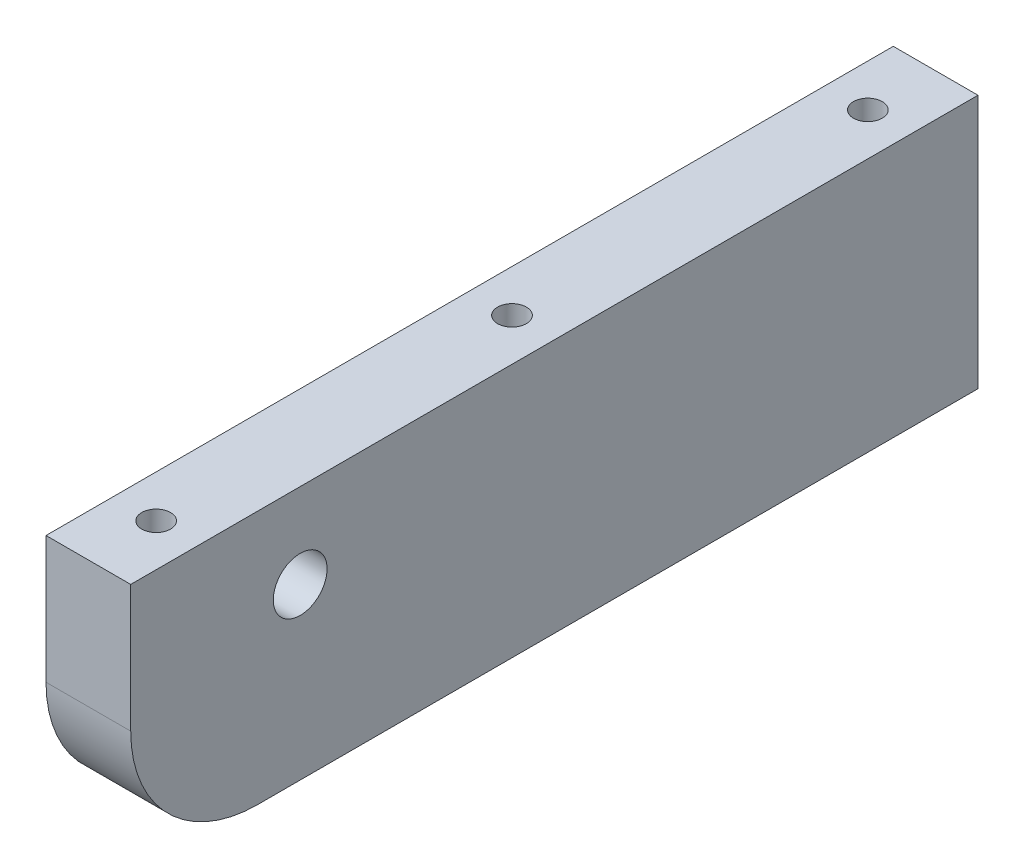
from build123d import *

# Parameters (mm, degrees)
SKETCH1_W                     = 100
SKETCH1_H                     = 30
SKETCH1_R                     = 3.175
BOSS_EXTRUDE1_DEPTH           = 10
FILLET1_R                     = 15
CBORE_FOR_M3_SHCS_D           = 3.4
CBORE_FOR_M3_SHCS_DEPTH       = 23
CBORE_FOR_M3_SHCS_CBORE_D     = 6.5
CBORE_FOR_M3_SHCS_CBORE_DEPTH = 3
CBORE_FOR_M3_SHCS_TIP         = 1.021463052


with BuildPart() as part:
    # Sketch1 → Boss-Extrude1 (new body)
    with BuildSketch(Plane(origin=(0, 0, 0), x_dir=(0, 0, -1), z_dir=(1, 0, 0))):
        Rectangle(SKETCH1_W, SKETCH1_H)
        with Locations((-30, 5)):
            Circle(SKETCH1_R, mode=Mode.SUBTRACT)
    extrude(amount=BOSS_EXTRUDE1_DEPTH)

    # Fillet1
    fillet1_edges = [part.edges().sort_by_distance(p)[0] for p in [
        (5, -15, 50),
    ]]
    fillet(fillet1_edges, radius=FILLET1_R)

    # CBORE for M3 SHCS
    with Locations(Plane(origin=(-616.293536786, 25, -1323.282701689), x_dir=(1, 0, 0), z_dir=(0, 1, 0))):
        with Locations((731.293536786, -1281.282701689), (731.293536786, -1359.282701689), (621.293536786, -1281.282701689), (621.293536786, -1365.282701689), (621.293536786, -1323.282701689), (731.293536786, -1320.282701689)):
            CounterBoreHole(CBORE_FOR_M3_SHCS_D / 2, CBORE_FOR_M3_SHCS_CBORE_D / 2, CBORE_FOR_M3_SHCS_CBORE_DEPTH, depth=CBORE_FOR_M3_SHCS_DEPTH)
            with Locations((0, 0, -(CBORE_FOR_M3_SHCS_DEPTH + CBORE_FOR_M3_SHCS_TIP / 2))):  # 118° drill point
                Cone(0, CBORE_FOR_M3_SHCS_D / 2, CBORE_FOR_M3_SHCS_TIP, mode=Mode.SUBTRACT)


solid = part.part
